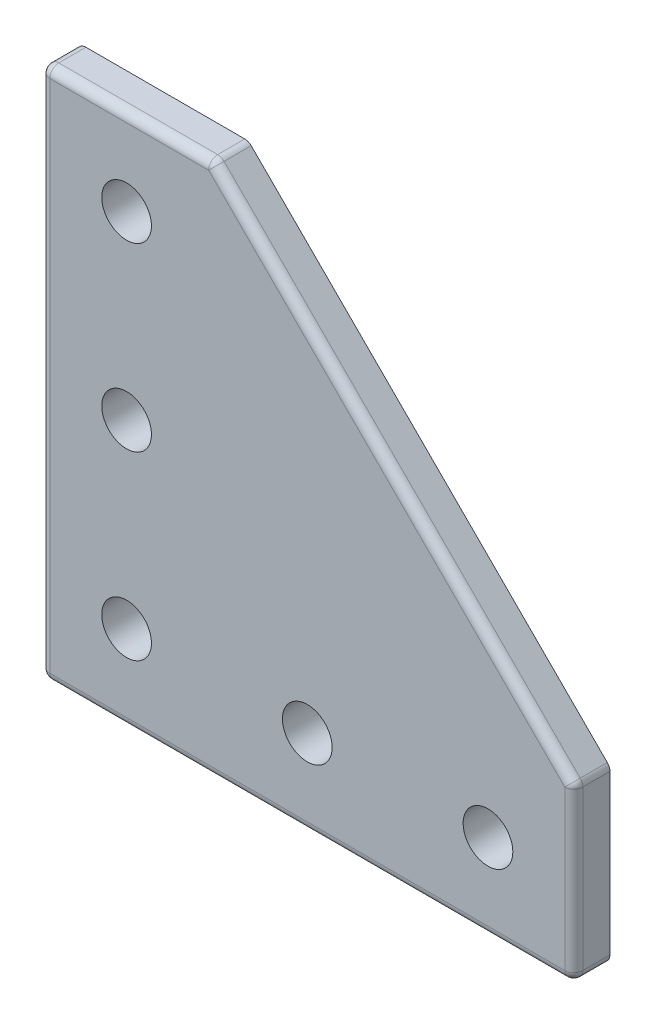
from build123d import *

# Parameters (mm, degrees)
SKETCH1_R           = 2.75
BOSS_EXTRUDE1_DEPTH = 2
FILLET1_R           = 1


with BuildPart() as part:
    # Sketch1 → Boss-Extrude1 (new body, symmetric)
    with BuildSketch(Plane.XY):
        Polygon((0, 0), (0, 59), (19, 59), (59, 19), (59, 0), align=None)
        with Locations((9.5, 9.5)):
            Circle(SKETCH1_R, mode=Mode.SUBTRACT)
        with Locations((29.5, 9.5)):
            Circle(SKETCH1_R, mode=Mode.SUBTRACT)
        with Locations((49.5, 9.5)):
            Circle(SKETCH1_R, mode=Mode.SUBTRACT)
        with Locations((9.5, 29.5)):
            Circle(SKETCH1_R, mode=Mode.SUBTRACT)
        with Locations((9.5, 49.5)):
            Circle(SKETCH1_R, mode=Mode.SUBTRACT)
    extrude(amount=BOSS_EXTRUDE1_DEPTH, both=True)

    # Fillet1
    fillet1_edges = [part.edges().sort_by_distance(p)[0] for p in [
        (39, 39, 2),
        (9.5, 59, 2),
        (0, 29.5, 2),
        (29.5, 0, 2),
        (59, 9.5, 2),
        (0, 0, 0),
        (0, 59, 0),
        (19, 59, 0),
        (59, 19, 0),
        (59, 0, 0),
    ]]
    fillet(fillet1_edges, radius=FILLET1_R)


solid = part.part
